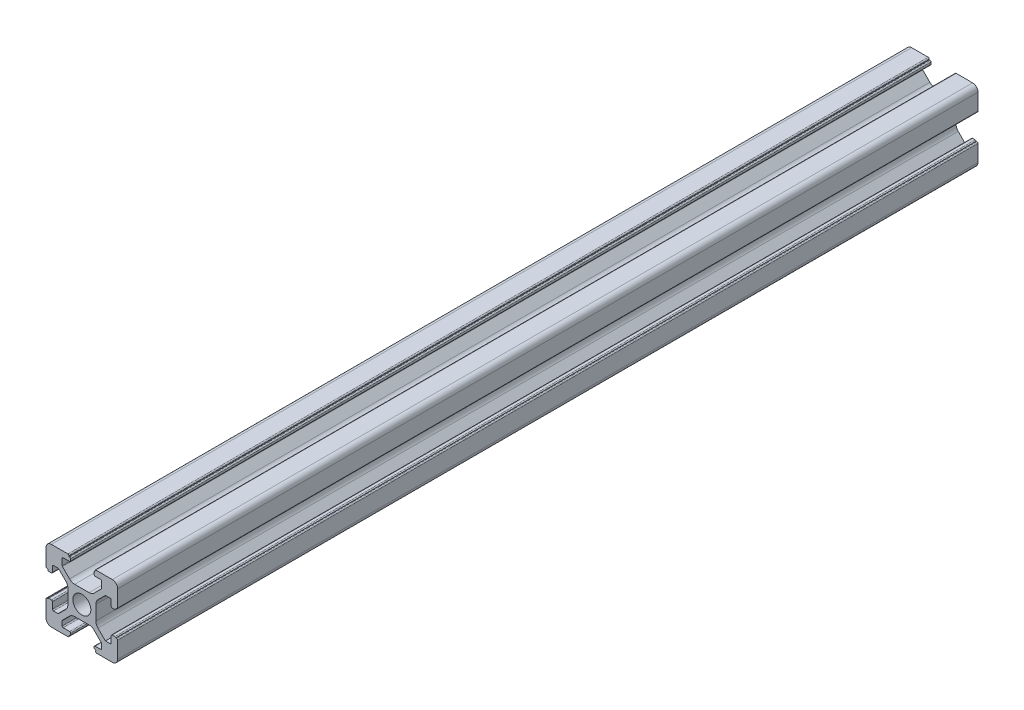
from build123d import *

# Parameters (mm, degrees)
MODEL_R             = 2.5
BOSS_EXTRUDE1_DEPTH = 240


with BuildPart() as part:
    # Model → Boss-Extrude1 (new body)
    with BuildSketch(Plane.XY):
        with BuildLine():
            Line((3.9, -0.3), (3.9, -2.310912704))
            ThreePointArc((3.9, -2.310912704), (4.052240935, -3.076279568), (4.485786438, -3.725126266))
            Line((4.485786438, -3.725126266), (6.560660172, -5.8))
            Line((6.560660172, -5.8), (7.9, -5.8))
            ThreePointArc((7.9, -5.8), (8.112132034, -5.712132034), (8.2, -5.5))
            Line((8.2, -5.5), (8.2, -3.7))
            ThreePointArc((8.2, -3.7), (8.287867966, -3.487867966), (8.5, -3.4))
            Line((8.5, -3.4), (9.2, -3.4))
            ThreePointArc((9.2, -3.4), (9.412132034, -3.487867966), (9.5, -3.7))
            Line((9.5, -3.7), (9.5, -3.6))
            Line((9.5, -3.6), (9.7, -3.6))
            ThreePointArc((9.7, -3.6), (9.912132034, -3.687867966), (10, -3.9))
            Line((10, -3.9), (10, -8.5))
            ThreePointArc((10, -8.5), (9.560660172, -9.560660172), (8.5, -10))
            Line((8.5, -10), (4.15825757, -10))
            ThreePointArc((4.15825757, -10), (3.907259562, -9.864316767), (3.883303028, -9.58))
            ThreePointArc((3.883303028, -9.58), (3.867332005, -9.390455488), (3.7, -9.3))
            ThreePointArc((3.7, -9.3), (3.487867966, -9.212132034), (3.4, -9))
            Line((3.4, -9), (3.4, -8.8))
            ThreePointArc((3.4, -8.8), (3.487867966, -8.587867966), (3.7, -8.5))
            Line((3.7, -8.5), (5.2, -8.5))
            ThreePointArc((5.2, -8.5), (5.412132034, -8.412132034), (5.5, -8.2))
            Line((5.5, -8.2), (5.5, -6.98492424))
            ThreePointArc((5.5, -6.98492424), (5.47716386, -6.870119211), (5.412132034, -6.772792206))
            Line((5.412132034, -6.772792206), (3.425126266, -4.785786438))
            ThreePointArc((3.425126266, -4.785786438), (2.776279568, -4.352240935), (2.010912703, -4.2))
            Line((2.010912703, -4.2), (0, -4.2))
            Line((0, -4.2), (-2.010912703, -4.2))
            ThreePointArc((-2.010912703, -4.2), (-2.776279568, -4.352240935), (-3.425126266, -4.785786438))
            Line((-3.425126266, -4.785786438), (-5.412132034, -6.772792206))
            ThreePointArc((-5.412132034, -6.772792206), (-5.47716386, -6.870119211), (-5.5, -6.984924241))
            Line((-5.5, -6.984924241), (-5.5, -8.2))
            ThreePointArc((-5.5, -8.2), (-5.412132034, -8.412132034), (-5.2, -8.5))
            Line((-5.2, -8.5), (-3.4, -8.5))
            ThreePointArc((-3.4, -8.5), (-3.187867966, -8.587867966), (-3.1, -8.8))
            Line((-3.1, -8.8), (-3.1, -9.2))
            ThreePointArc((-3.1, -9.2), (-3.187867966, -9.412132034), (-3.4, -9.5))
            ThreePointArc((-3.4, -9.5), (-3.541421356, -9.558578644), (-3.6, -9.7))
            ThreePointArc((-3.6, -9.7), (-3.687867966, -9.912132034), (-3.9, -10))
            Line((-3.9, -10), (-8.5, -10))
            ThreePointArc((-8.5, -10), (-9.560660172, -9.560660172), (-10, -8.5))
            Line((-10, -8.5), (-10, -3.9))
            ThreePointArc((-10, -3.9), (-9.912132034, -3.687867966), (-9.7, -3.6))
            Line((-9.7, -3.6), (-9.5, -3.6))
            Line((-9.5, -3.6), (-9.5, -3.7))
            ThreePointArc((-9.5, -3.7), (-9.412132034, -3.487867966), (-9.2, -3.4))
            Line((-9.2, -3.4), (-8.5, -3.4))
            ThreePointArc((-8.5, -3.4), (-8.287867966, -3.487867966), (-8.2, -3.7))
            Line((-8.2, -3.7), (-8.2, -5.5))
            ThreePointArc((-8.2, -5.5), (-8.112132034, -5.712132034), (-7.9, -5.8))
            Line((-7.9, -5.8), (-6.68492424, -5.8))
            ThreePointArc((-6.68492424, -5.8), (-6.570119211, -5.77716386), (-6.472792206, -5.712132034))
            Line((-6.472792206, -5.712132034), (-4.485786438, -3.725126266))
            ThreePointArc((-4.485786438, -3.725126266), (-4.052240935, -3.076279568), (-3.9, -2.310912704))
            Line((-3.9, -2.310912704), (-3.9, -0.3))
            Line((-3.9, -0.3), (-3.9, 1.710912703))
            ThreePointArc((-3.9, 1.710912703), (-4.052240935, 2.476279568), (-4.485786438, 3.125126266))
            Line((-4.485786438, 3.125126266), (-6.472792206, 5.112132034))
            ThreePointArc((-6.472792206, 5.112132034), (-6.570119211, 5.17716386), (-6.68492424, 5.2))
            Line((-6.68492424, 5.2), (-7.9, 5.2))
            ThreePointArc((-7.9, 5.2), (-8.112132034, 5.112132034), (-8.2, 4.9))
            Line((-8.2, 4.9), (-8.2, 3.4))
            ThreePointArc((-8.2, 3.4), (-8.287867966, 3.187867966), (-8.5, 3.1))
            Line((-8.5, 3.1), (-9.2, 3.1))
            ThreePointArc((-9.2, 3.1), (-9.412132034, 3.187867966), (-9.5, 3.4))
            Line((-9.5, 3.4), (-9.5, 3.6))
            Line((-9.5, 3.6), (-9.7, 3.6))
            ThreePointArc((-9.7, 3.6), (-9.912132034, 3.687867966), (-10, 3.9))
            Line((-10, 3.9), (-10, 8.5))
            ThreePointArc((-10, 8.5), (-9.560660172, 9.560660172), (-8.5, 10))
            Line((-8.5, 10), (-3.9, 10))
            ThreePointArc((-3.9, 10), (-3.687867966, 9.912132034), (-3.6, 9.7))
            Line((-3.6, 9.7), (-3.6, 9.5))
            Line((-3.6, 9.5), (-3.4, 9.5))
            ThreePointArc((-3.4, 9.5), (-3.187867966, 9.412132034), (-3.1, 9.2))
            Line((-3.1, 9.2), (-3.1, 8.7))
            ThreePointArc((-3.1, 8.7), (-3.187867966, 8.487867965), (-3.4, 8.4))
            Line((-3.4, 8.4), (-5.2, 8.4))
            ThreePointArc((-5.2, 8.4), (-5.412132034, 8.312132034), (-5.5, 8.1))
            Line((-5.5, 8.1), (-5.5, 6.38492424))
            ThreePointArc((-5.5, 6.38492424), (-5.47716386, 6.270119211), (-5.412132034, 6.172792206))
            Line((-5.412132034, 6.172792206), (-3.425126266, 4.185786438))
            ThreePointArc((-3.425126266, 4.185786438), (-2.776279568, 3.752240935), (-2.010912703, 3.6))
            Line((-2.010912703, 3.6), (0, 3.6))
            Line((0, 3.6), (2.010912703, 3.6))
            ThreePointArc((2.010912703, 3.6), (2.776279568, 3.752240935), (3.425126266, 4.185786438))
            Line((3.425126266, 4.185786438), (5.412132034, 6.172792206))
            ThreePointArc((5.412132034, 6.172792206), (5.47716386, 6.270119211), (5.5, 6.38492424))
            Line((5.5, 6.38492424), (5.5, 8.1))
            ThreePointArc((5.5, 8.1), (5.412132034, 8.312132034), (5.2, 8.4))
            Line((5.2, 8.4), (3.7, 8.4))
            ThreePointArc((3.7, 8.4), (3.487867966, 8.487867965), (3.4, 8.7))
            Line((3.4, 8.7), (3.4, 9.2))
            ThreePointArc((3.4, 9.2), (3.487867966, 9.412132034), (3.7, 9.5))
            Line((3.7, 9.5), (3.6, 9.5))
            Line((3.6, 9.5), (3.6, 9.7))
            ThreePointArc((3.6, 9.7), (3.687867966, 9.912132034), (3.9, 10))
            Line((3.9, 10), (8.5, 10))
            ThreePointArc((8.5, 10), (9.560660172, 9.560660172), (10, 8.5))
            Line((10, 8.5), (10, 3.9))
            ThreePointArc((10, 3.9), (9.912132034, 3.687867966), (9.7, 3.6))
            Line((9.7, 3.6), (9.5, 3.6))
            Line((9.5, 3.6), (9.5, 3.4))
            ThreePointArc((9.5, 3.4), (9.412132034, 3.187867966), (9.2, 3.1))
            Line((9.2, 3.1), (8.5, 3.1))
            ThreePointArc((8.5, 3.1), (8.287867966, 3.187867966), (8.2, 3.4))
            Line((8.2, 3.4), (8.2, 4.9))
            ThreePointArc((8.2, 4.9), (8.112132034, 5.112132034), (7.9, 5.2))
            Line((7.9, 5.2), (6.684924241, 5.2))
            ThreePointArc((6.684924241, 5.2), (6.570119211, 5.17716386), (6.472792206, 5.112132034))
            Line((6.472792206, 5.112132034), (4.485786438, 3.125126266))
            ThreePointArc((4.485786438, 3.125126266), (4.052240935, 2.476279568), (3.9, 1.710912703))
            Line((3.9, 1.710912703), (3.9, -0.3))
        make_face()
        with Locations((0, -0.3)):
            Circle(MODEL_R, mode=Mode.SUBTRACT)
    extrude(amount=BOSS_EXTRUDE1_DEPTH)


solid = part.part
